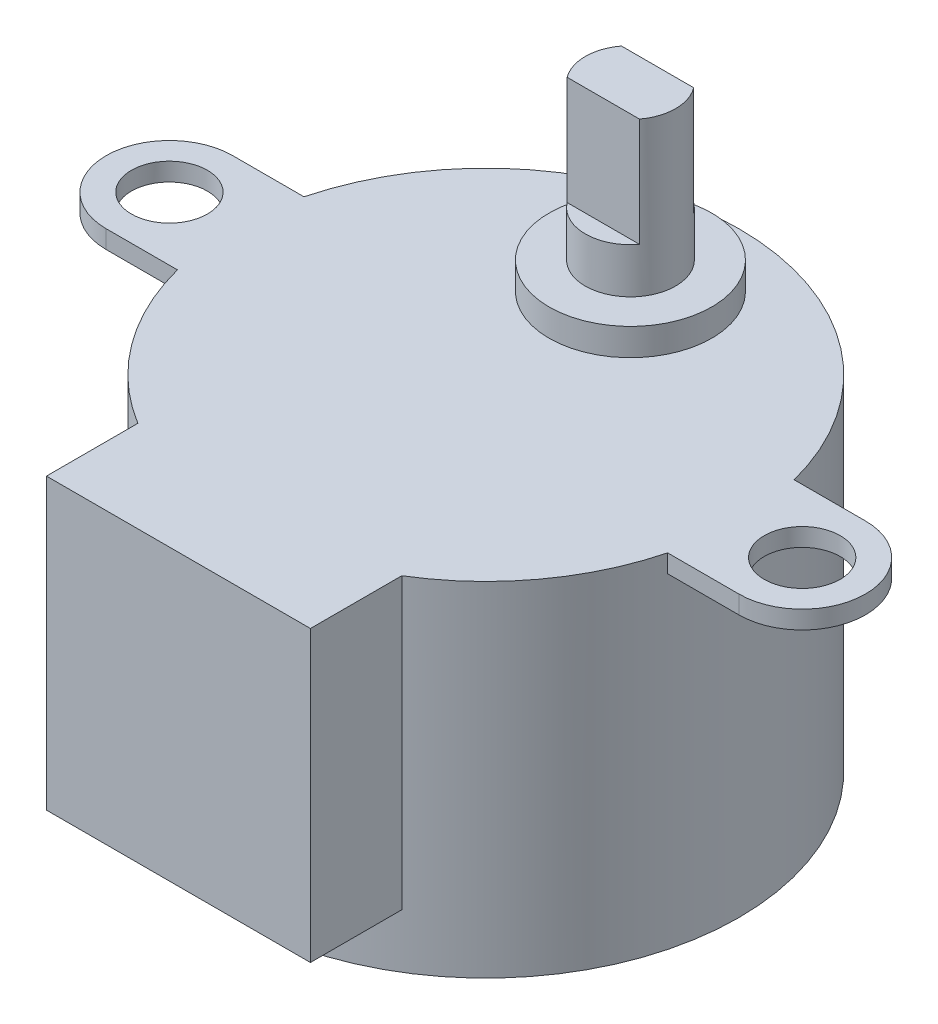
from build123d import *
from build123d.topology import SkipClean

# Parameters (mm, degrees)
SKETCH1_R           = 14
BOSS_EXTRUDE1_DEPTH = 19
BOSS_EXTRUDE2_DEPTH = 1
CUT_EXTRUDE1_REACH  = 33.591
SKETCH3_R           = 2.1
BOSS_EXTRUDE3_DEPTH = 16
SKETCH5_R           = 4.5
BOSS_EXTRUDE4_DEPTH = 1.5
SKETCH6_R           = 2.5
BOSS_EXTRUDE5_DEPTH = 2.5
BOSS_EXTRUDE6_DEPTH = 6


with BuildPart() as part:
    # Sketch1 → Boss-Extrude1 (new body)
    with BuildSketch(Plane(origin=(0, 0, 0), x_dir=(1, 0, 0), z_dir=(0, 1, 0))):
        with Locations(Location((0, 0, 0), (0, 0, 270))):
            Circle(SKETCH1_R)
    extrude(amount=BOSS_EXTRUDE1_DEPTH)

    # Sketch2 → Boss-Extrude2 (add)
    with BuildSketch(Plane(origin=(0, 19, 0), x_dir=(1, 0, 0), z_dir=(0, 1, 0))):
        with BuildLine():
            Line((13.555441712, 3.5), (17.5, 3.5))
            ThreePointArc((17.5, 3.5), (21, 0), (17.5, -3.5))
            Line((17.5, -3.5), (13.555441712, -3.5))
            ThreePointArc((13.555441712, -3.5), (14, 0), (13.555441712, 3.5))
        make_face()
        with BuildLine():
            Line((-13.555441712, -3.5), (-17.5, -3.5))
            ThreePointArc((-17.5, -3.5), (-21, 0), (-17.5, 3.5))
            Line((-17.5, 3.5), (-13.555441712, 3.5))
            ThreePointArc((-13.555441712, 3.5), (-14, 0), (-13.555441712, -3.5))
        make_face()
    extrude(amount=-BOSS_EXTRUDE2_DEPTH)

    # Sketch3 → Cut-Extrude1 (cut, up to next)
    with BuildSketch(Plane(origin=(0, 19, 0), x_dir=(1, 0, 0), z_dir=(0, 1, 0)), mode=Mode.PRIVATE) as cut_extrude1_sk1:
        with Locations(Location((17.5, 0, 0), (0, 0, 270))):
            Circle(SKETCH3_R)
    cut_extrude1_tool1 = extrude(cut_extrude1_sk1.sketch, amount=-CUT_EXTRUDE1_REACH, mode=Mode.PRIVATE) & part.part
    # Sketch3 → Cut-Extrude1 (cut, up to next)
    with BuildSketch(Plane(origin=(0, 19, 0), x_dir=(1, 0, 0), z_dir=(0, 1, 0)), mode=Mode.PRIVATE) as cut_extrude1_sk2:
        with Locations(Location((-17.5, 0, 0), (0, 0, 270))):
            Circle(SKETCH3_R)
    cut_extrude1_tool2 = extrude(cut_extrude1_sk2.sketch, amount=-CUT_EXTRUDE1_REACH, mode=Mode.PRIVATE) & part.part
    add(cut_extrude1_tool1.solids().sort_by_distance((17.5, 19, 0))[0], mode=Mode.SUBTRACT)
    add(cut_extrude1_tool2.solids().sort_by_distance((-17.5, 19, 0))[0], mode=Mode.SUBTRACT)

    # Sketch4 → Boss-Extrude3 (add)
    with BuildSketch(Plane(origin=(0, 19, 0), x_dir=(1, 0, 0), z_dir=(0, 1, 0))):
        with BuildLine():
            Line((7.3, -11.94612908), (7.3, -17))
            Line((7.3, -17), (-7.3, -17))
            Line((-7.3, -17), (-7.3, -11.94612908))
            ThreePointArc((-7.3, -11.94612908), (0, -14), (7.3, -11.94612908))
        make_face()
    extrude(amount=-BOSS_EXTRUDE3_DEPTH)

    # Sketch5 → Boss-Extrude4 (add)
    with BuildSketch(Plane(origin=(0, 19, 0), x_dir=(1, 0, 0), z_dir=(0, 1, 0))):
        with Locations(Location((0, 8, 0), (0, 0, 270))):
            Circle(SKETCH5_R)
    extrude(amount=BOSS_EXTRUDE4_DEPTH)

    # Sketch6 → Boss-Extrude5 (add)
    with BuildSketch(Plane(origin=(0, 20.5, 0), x_dir=(1, 0, 0), z_dir=(0, 1, 0))):
        with Locations(Location((0, 8, 0), (0, 0, 270))):
            Circle(SKETCH6_R)
    extrude(amount=BOSS_EXTRUDE5_DEPTH)

    # Sketch7 → Boss-Extrude6 (add)
    with SkipClean():  # the faces are left unmerged after this step: merging them gives an invalid solid
        with BuildSketch(Plane(origin=(0, 23, 0), x_dir=(1, 0, 0), z_dir=(0, 1, 0))):
            with BuildLine():
                Line((-2, 9.5), (2, 9.5))
                ThreePointArc((2, 9.5), (2.5, 8), (2, 6.5))
                Line((2, 6.5), (-2, 6.5))
                ThreePointArc((-2, 6.5), (-2.5, 8), (-2, 9.5))
            make_face()
        extrude(amount=BOSS_EXTRUDE6_DEPTH)


solid = part.part
